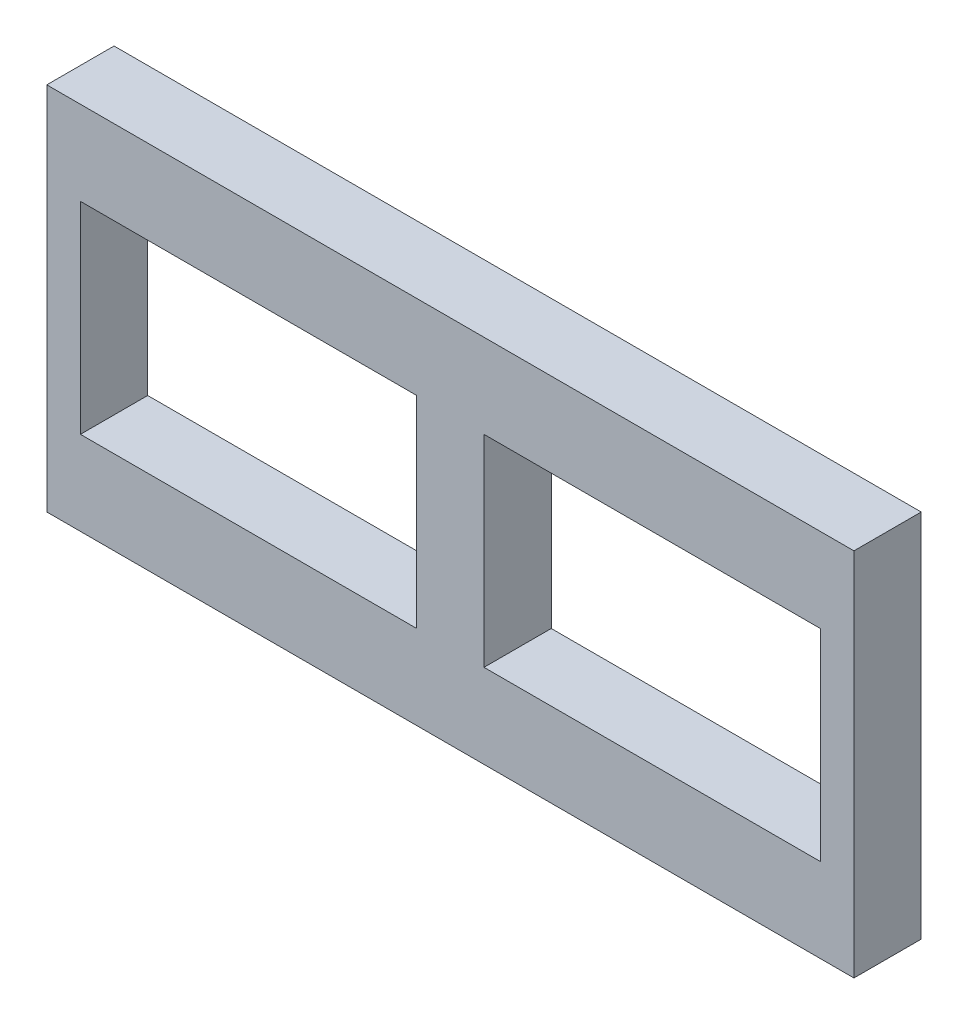
from build123d import *

# Parameters (mm, degrees)
SKETCH_1_W          = 120
SKETCH_1_H          = 55
EXTRUDE_1_DEPTH     = 10
SKETCH_2_W          = 50
SKETCH_2_H          = 30
CUT_EXTRUDE_1_DEPTH = 10


with BuildPart() as part:
    # 草圖1 → 填料-伸長1 (new body)
    with BuildSketch(Plane.XY):
        Rectangle(SKETCH_1_W, SKETCH_1_H)
    extrude(amount=EXTRUDE_1_DEPTH)

    # 草圖2 → 除料-伸長1 (cut)
    with BuildSketch(Plane(origin=(0, 0, 0), x_dir=(-1, 0, 0), z_dir=(0, 0, -1))):
        with Locations((-30, 0)):
            Rectangle(SKETCH_2_W, SKETCH_2_H)
        with Locations((30, 0)):
            Rectangle(SKETCH_2_W, SKETCH_2_H)
    extrude(amount=-CUT_EXTRUDE_1_DEPTH, mode=Mode.SUBTRACT)


solid = part.part
